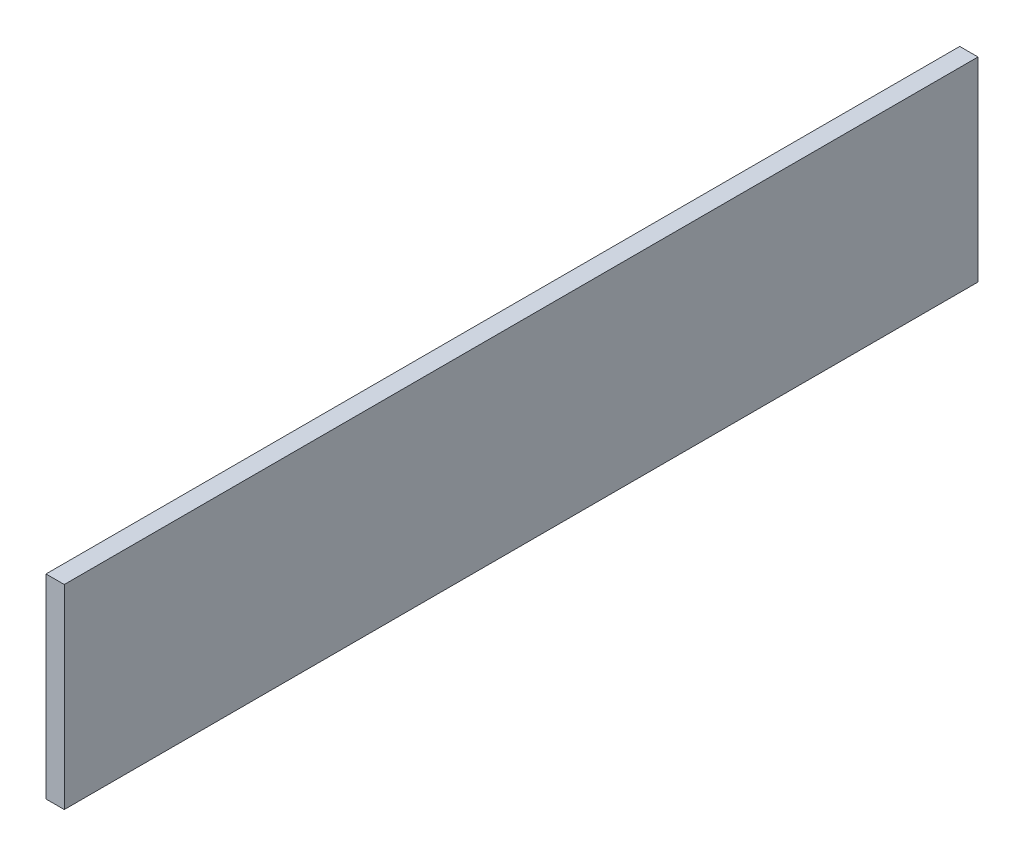
from build123d import *

# Parameters (mm, degrees)
SKETCH1_W           = 1500
SKETCH1_H           = 320
BOSS_EXTRUDE1_DEPTH = 30


with BuildPart() as part:
    # Sketch1 → Boss-Extrude1 (new body)
    with BuildSketch(Plane(origin=(0, 0, 0), x_dir=(0, 0, -1), z_dir=(1, 0, 0))):
        with Locations((-101.851851852, 258.055555556)):
            Rectangle(SKETCH1_W, SKETCH1_H)
    extrude(amount=BOSS_EXTRUDE1_DEPTH)


solid = part.part
